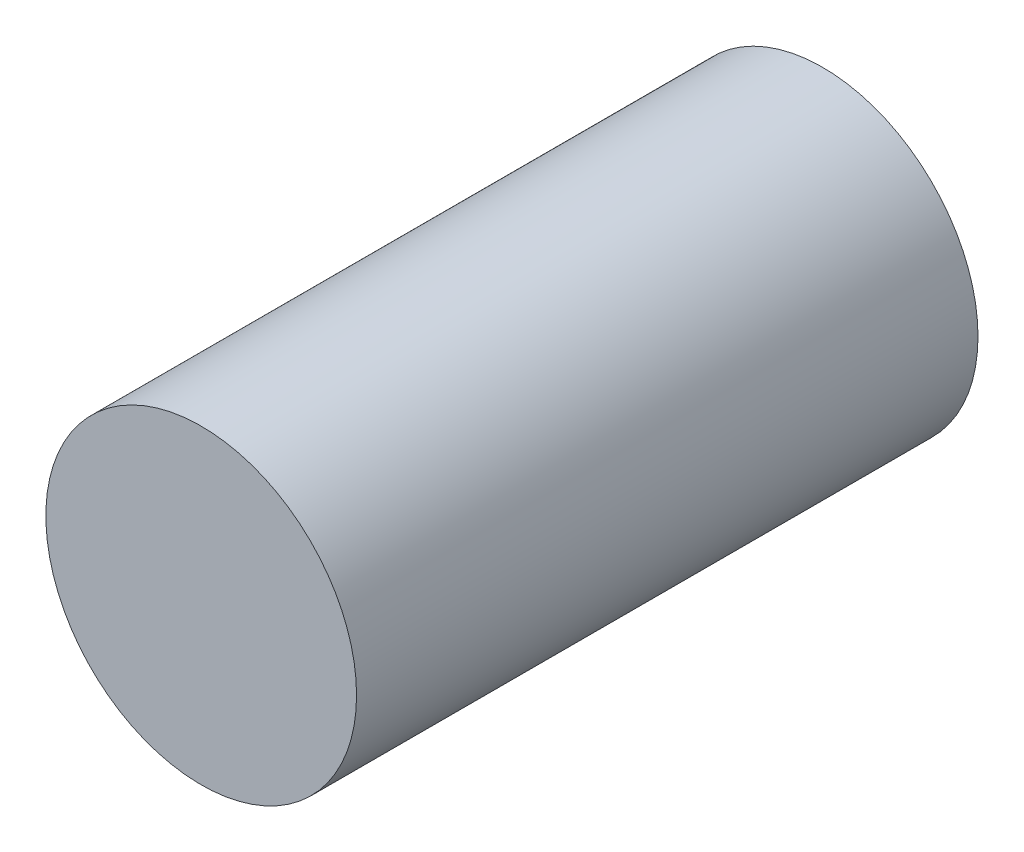
from build123d import *

# Parameters (mm, degrees)
ESQUISSE1_R        = 4
BOSS_EXTRU_1_DEPTH = 16


with BuildPart() as part:
    # Esquisse1 → Boss.-Extru.1 (new body)
    with BuildSketch(Plane.XY):
        Circle(ESQUISSE1_R)
    extrude(amount=BOSS_EXTRU_1_DEPTH)


solid = part.part
